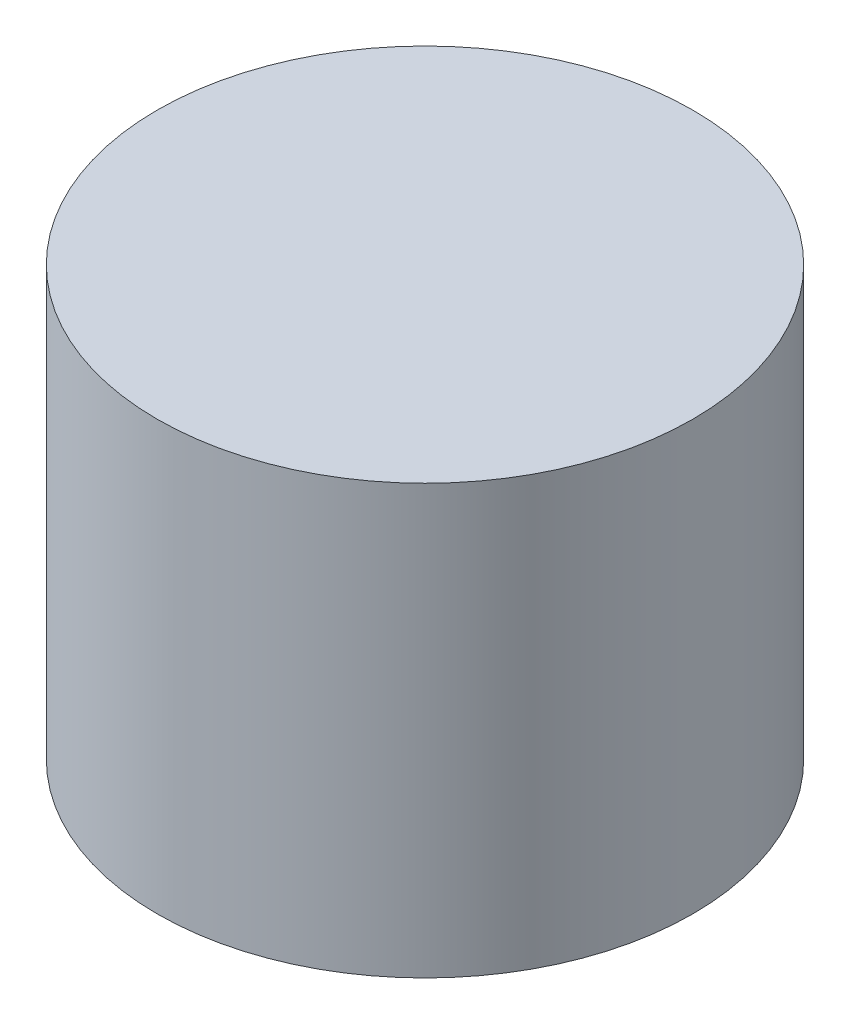
from build123d import *

# Parameters (mm, degrees)
SKETCH1_R           = 63.5
BOSS_EXTRUDE1_DEPTH = 101.6


with BuildPart() as part:
    # Sketch1 → Boss-Extrude1 (new body)
    with BuildSketch(Plane(origin=(0, 0, 0), x_dir=(1, 0, 0), z_dir=(0, 1, 0))):
        Circle(SKETCH1_R)
    extrude(amount=BOSS_EXTRUDE1_DEPTH)


solid = part.part
